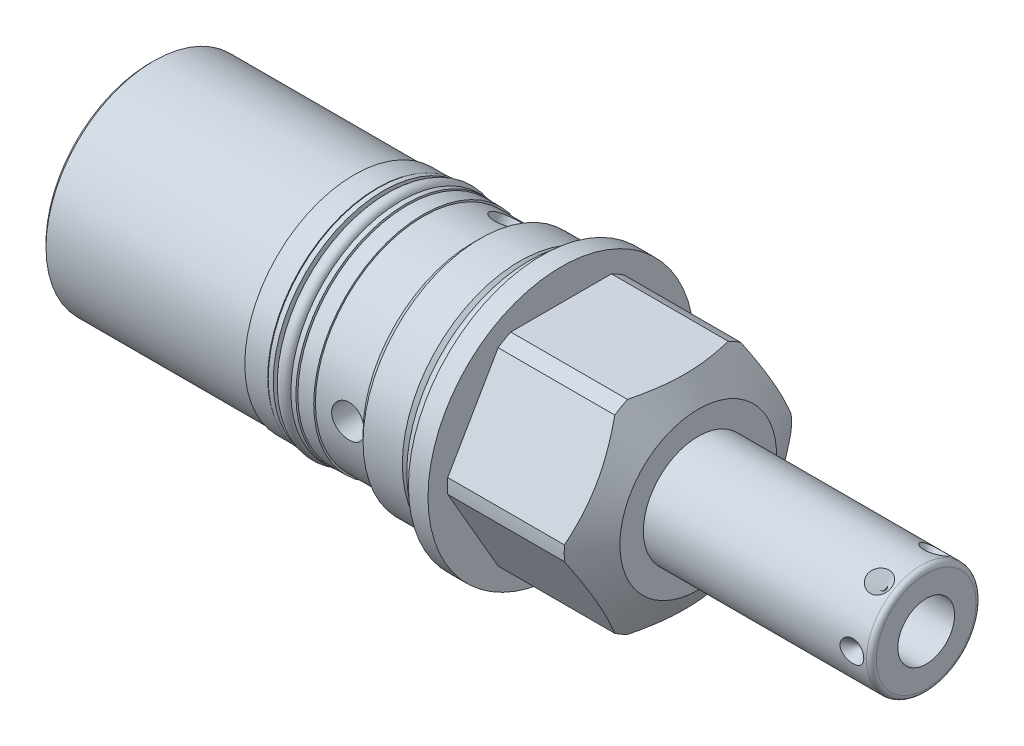
from build123d import *

# Parameters (mm, degrees)
SKETCH2_OUTSIDE_W  = 82.938
SKETCH2_OUTSIDE_H  = 82.938
CUT_EXTRUDE1_DEPTH = 27.7876
CIRPATTERN1_COUNT  = 6
SKETCH6_W          = 13.97
SKETCH6_H          = 0.3429
SKETCH7_R          = 3.1369
CUT_EXTRUDE2_DEPTH = 0.762
SKETCH8_W          = 6.1087
SKETCH8_H          = 2.032
SKETCH9_W          = 1.016
SKETCH9_H          = 2.1844
SKETCH10_W         = 3.3147
SKETCH10_H         = 12.7
CIRPATTERN2_COUNT  = 3
CHAMFER1_SIZE      = 0.762
SKETCH11_R         = 1.4732
SKETCH12_R         = 1.3081
SKETCH14_R         = 17.7927
EXTRUDE1_DEPTH     = 0.508
SKETCH15_R         = 6.1849
CUT_EXTRUDE3_DEPTH = 0.508


with BuildPart() as part:
    # Sketch1 → Revolve1 (revolve)
    with BuildSketch(Plane.XY, mode=Mode.PRIVATE) as revolve1_sk:
        Polygon((0, 26.9875), (3.9624, 26.9875), (3.9624, 23.0251), (27.62188784, 23.0251), (31.75, 15.875), (31.75, 0), (-79.375, 0), (-79.375, 21.844), (-13.9954, 21.844), (-13.9954, 22.1869), (-12.3698, 23.8125), (-4.4069, 23.8125), (-2.8956, 22.3012), (0, 22.3012), align=None)
    revolve(revolve1_sk.sketch.rotate(Axis((0, 0, 0), (1, 0, 0)), 90), axis=Axis((0, 0, 0), (1, 0, 0)))  # turned: the seam where the file's is

    # Sketch2 outside → Cut-Extrude1 (cut)
    with BuildSketch(Plane(origin=(31.75, 0, 0), x_dir=(0, 0, -1), z_dir=(1, 0, 0))):
        Rectangle(SKETCH2_OUTSIDE_W, SKETCH2_OUTSIDE_H)
        Polygon((11.91506618, 20.6375), (-11.91506618, 20.6375), (-23.830132361, 0), (-11.91506618, -20.6375), (11.91506618, -20.6375), (23.830132361, 0), align=None, mode=Mode.SUBTRACT)
    extrude(amount=-CUT_EXTRUDE1_DEPTH, mode=Mode.SUBTRACT)

    # Sketch3 → Revolve2 (revolve)
    with BuildSketch(Plane.XY, mode=Mode.PRIVATE) as revolve2_sk:
        with BuildLine():
            Line((31.75, 11.1125), (76.962, 11.1125))
            ThreePointArc((76.962, 11.1125), (77.68042049, 10.81492049), (77.978, 10.0965))
            Line((77.978, 10.0965), (77.978, 0))
            Line((77.978, 0), (31.75, 0))
            Line((31.75, 0), (31.75, 11.1125))
        make_face()
    revolve(revolve2_sk.sketch.rotate(Axis((0, 0, 0), (1, 0, 0)), 90), axis=Axis((0, 0, 0), (1, 0, 0)))  # turned: the seam where the file's is

    # Sketch4 → Cut-Revolve1 (revolve, cut)
    with BuildSketch(Plane(origin=(0, 0, 0), x_dir=(1, 0, 0), z_dir=(0, 1, 0)), mode=Mode.PRIVATE) as cut_revolve1_sk:
        Polygon((76.4286, 11.1125), (74.0156, 11.1125), (74.0156, 8.6995), align=None)
    cut_revolve1 = revolve(cut_revolve1_sk.sketch.rotate(Axis((74.0156, 0, -10.073804773), (0, 0, 1)), 180), axis=Axis((74.0156, 0, -10.073804773), (0, 0, 1)), mode=Mode.SUBTRACT)  # turned: the seam where the file's is

    # CirPattern1: Cut-Revolve1 ×6 about axis
    cirpattern1_axis = Axis((0, 0, 0), (-1, 0, 0))
    for i in range(1, CIRPATTERN1_COUNT):
        add(cut_revolve1.rotate(cirpattern1_axis, i * 360 / CIRPATTERN1_COUNT), mode=Mode.SUBTRACT)

    # Sketch5 → Cut-Revolve2 (revolve, cut)
    with BuildSketch(Plane.XY, mode=Mode.PRIVATE) as cut_revolve2_sk:
        Polygon((77.978, 5.7531), (60.96, 5.7531), (57.503188773, 0), (77.978, 0), align=None)
    revolve(cut_revolve2_sk.sketch.rotate(Axis((0, 0, 0), (1, 0, 0)), 90), axis=Axis((0, 0, 0), (1, 0, 0)), mode=Mode.SUBTRACT)  # turned: the seam where the file's is

    # Sketch6 → Revolve3 (revolve)
    with BuildSketch(Plane.XY, mode=Mode.PRIVATE) as revolve3_sk:
        with Locations((-30.988, 22.01545)):
            Rectangle(SKETCH6_W, SKETCH6_H)
    revolve(revolve3_sk.sketch.rotate(Axis((0, 0, 0), (-1, 0, 0)), 270), axis=Axis((0, 0, 0), (-1, 0, 0)))  # turned: the seam where the file's is

    # Sketch7 → Cut-Extrude2 (cut)
    with BuildSketch(Plane.ZY.offset(79.375)):
        Circle(SKETCH7_R)
    extrude(amount=-CUT_EXTRUDE2_DEPTH, mode=Mode.SUBTRACT)

    # Sketch8 → Cut-Revolve3 (revolve, cut)
    with BuildSketch(Plane.XY, mode=Mode.PRIVATE) as cut_revolve3_sk:
        with Locations((-30.27045, 21.1709)):
            Rectangle(SKETCH8_W, SKETCH8_H)
    revolve(cut_revolve3_sk.sketch.rotate(Axis((0, 0, 0), (-1, 0, 0)), 270), axis=Axis((0, 0, 0), (-1, 0, 0)), mode=Mode.SUBTRACT)  # turned: the seam where the file's is

    # Sketch9 → Revolve4 (revolve)
    with BuildSketch(Plane.XY, mode=Mode.PRIVATE) as revolve4_sk:
        with Locations((-27.9781, 21.2471)):
            Rectangle(SKETCH9_W, SKETCH9_H)
        with Locations((-32.5628, 21.2471)):
            Rectangle(SKETCH9_W, SKETCH9_H)
    revolve(revolve4_sk.sketch.rotate(Axis((0, 0, 0), (-1, 0, 0)), 270), axis=Axis((0, 0, 0), (-1, 0, 0)))  # turned: the seam where the file's is

    # Sketch10 → Cut-Revolve4 (revolve, cut)
    with BuildSketch(Plane(origin=(0, 0, 0), x_dir=(1, 0, 0), z_dir=(0, 1, 0))):
        with Locations((-19.05635, -17.4625)):
            Rectangle(SKETCH10_W, SKETCH10_H)
    cut_revolve4 = revolve(axis=Axis((-17.399, 0, -23.036850257), (0, 0, 1)), mode=Mode.SUBTRACT)

    # CirPattern2: Cut-Revolve4 ×3 about axis
    cirpattern2_axis = Axis((0, 0, 0), (1, 0, 0))
    for i in range(1, CIRPATTERN2_COUNT):
        add(cut_revolve4.rotate(cirpattern2_axis, i * 360 / CIRPATTERN2_COUNT), mode=Mode.SUBTRACT)

    # Chamfer1
    chamfer1_edges = [part.edges().sort_by_distance(p)[0] for p in [
        (-79.375, 0, -21.844),
    ]]
    chamfer(chamfer1_edges, length=CHAMFER1_SIZE)

    # Sketch13 → Cut-Revolve5 (revolve, cut)
    with BuildSketch(Plane.XY, mode=Mode.PRIVATE) as cut_revolve5_sk:
        Polygon((-79.375, 6.1849), (-76.8096, 5.639607397), (-76.148392603, 4.9784), (-65.1002, 4.9784), (-65.1002, 0), (-79.375, 0), align=None)
    revolve(cut_revolve5_sk.sketch.rotate(Axis((-63.275446536, 0, 0), (1, 0, 0)), 90), axis=Axis((-63.275446536, 0, 0), (1, 0, 0)), mode=Mode.SUBTRACT)  # turned: the seam where the file's is

    # Sketch14 → Extrude1 (add)
    with BuildSketch(Plane.ZY.offset(79.375)):
        with Locations(Location((0, 0, 0), (0, 0, 180))):  # turned: the seam where the file's is
            Circle(SKETCH14_R)
    extrude(amount=EXTRUDE1_DEPTH)

    # Sketch15 → Cut-Extrude3 (cut)
    with BuildSketch(Plane.ZY.offset(79.883)):
        Circle(SKETCH15_R)
    extrude(amount=-CUT_EXTRUDE3_DEPTH, mode=Mode.SUBTRACT)


with BuildPart() as body_2:
    # Sketch11 → Revolve5 (revolve)
    with BuildSketch(Plane.XY, mode=Mode.PRIVATE) as revolve5_sk:
        with Locations((-1.4732, 23.7744)):
            Circle(SKETCH11_R)
    revolve(revolve5_sk.sketch.rotate(Axis((0, 0, 0), (1, 0, 0)), 90), axis=Axis((0, 0, 0), (1, 0, 0)))  # turned: the seam where the file's is


with BuildPart() as body_3:
    # Sketch12 → Revolve7 (revolve)
    with BuildSketch(Plane.XY, mode=Mode.PRIVATE) as revolve7_sk:
        with Locations((-30.27045, 21.463)):
            Circle(SKETCH12_R)
    revolve(revolve7_sk.sketch.rotate(Axis((0, 0, 0), (-1, 0, 0)), 270), axis=Axis((0, 0, 0), (-1, 0, 0)))  # turned: the seam where the file's is


solid = Compound([part.part, body_2.part, body_3.part])
